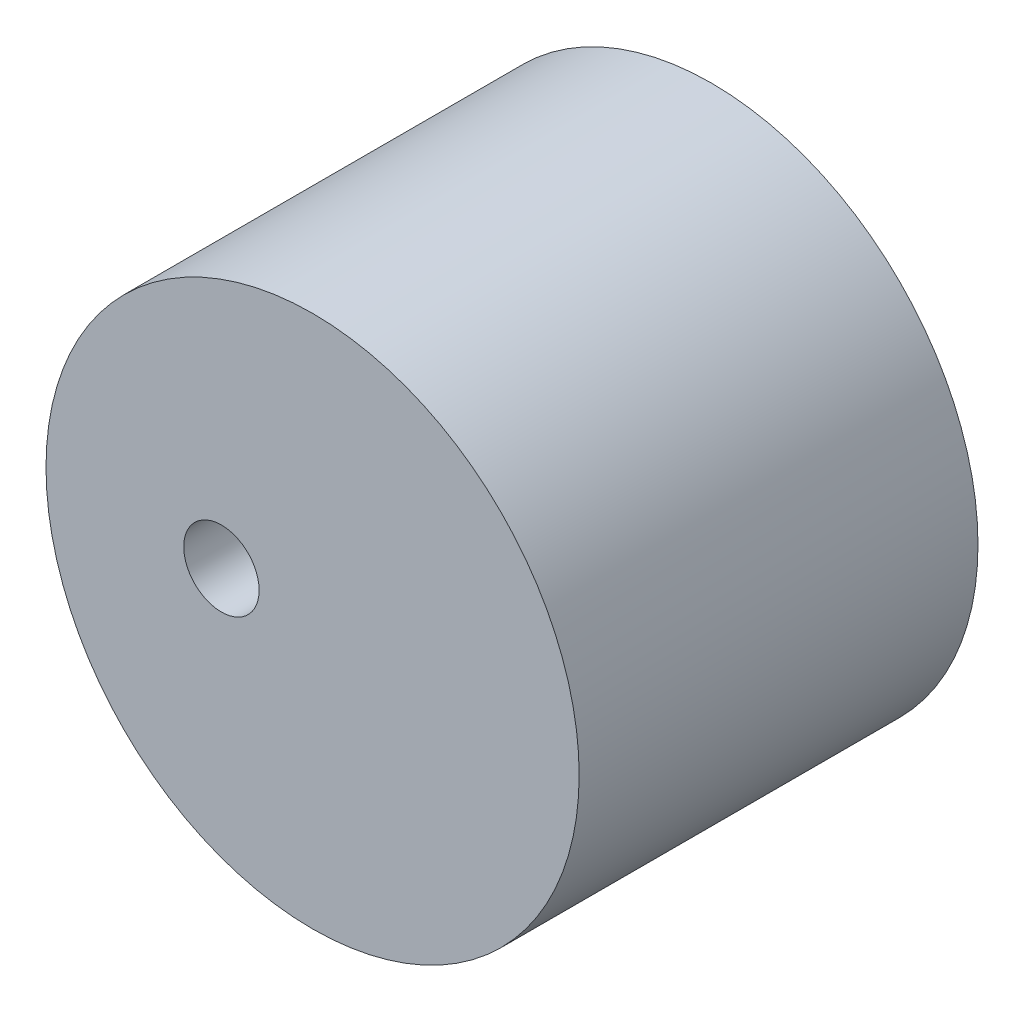
from build123d import *

# Parameters (mm, degrees)
SKETCH11_R           = 23.39375
SKETCH11_R_2         = 3.3085
BOSS_EXTRUDE13_DEPTH = 35


with BuildPart() as part:
    # Sketch11 → Boss-Extrude13 (new body)
    with BuildSketch(Plane.XY):
        Circle(SKETCH11_R)
        with Locations((-8, 0)):
            Circle(SKETCH11_R_2, mode=Mode.SUBTRACT)
    extrude(amount=BOSS_EXTRUDE13_DEPTH)


solid = part.part
